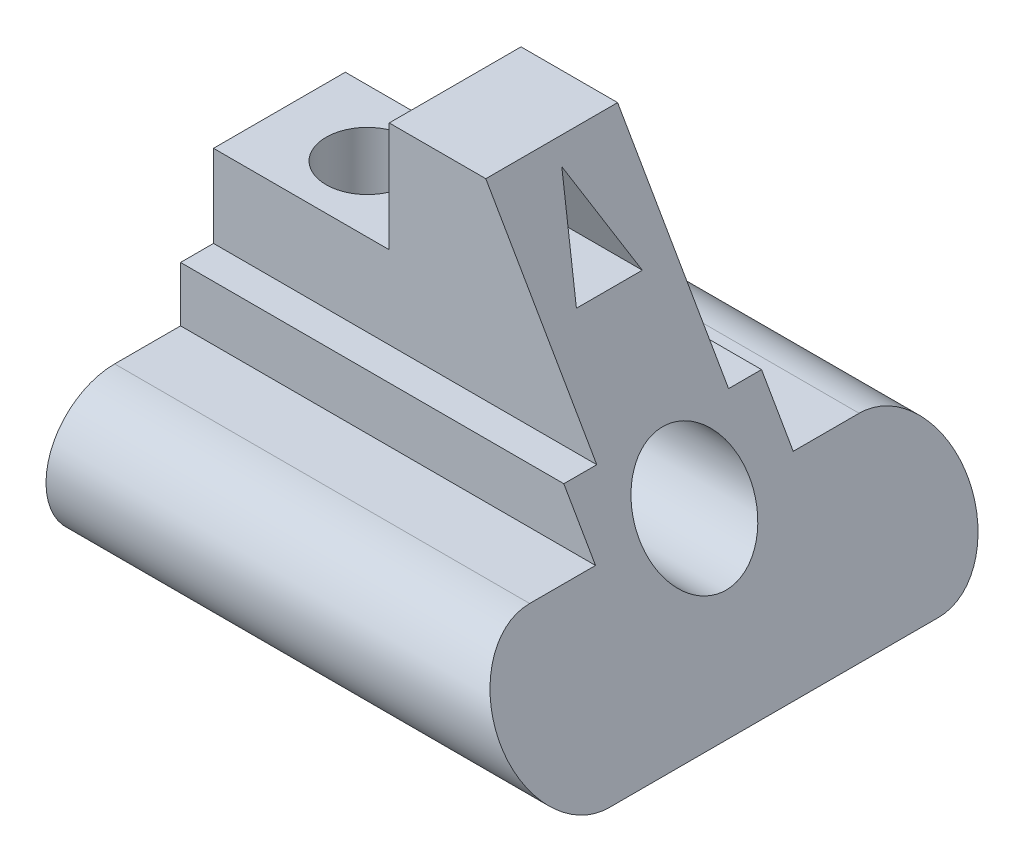
from build123d import *

# Parameters (mm, degrees)
SKETCH3_W               = 24
SKETCH3_H               = 35
BOSS_EXTRUDE1_DEPTH     = 90
SKETCH4_R               = 10
CUT_EXTRUDE1_DEPTH      = 91
SKETCH6_W               = 32
SKETCH6_H               = 24
CUT_EXTRUDE2_DEPTH      = 20
CUT_EXTRUDE4_REACH      = 52
SKETCH7_R               = 7.5
CUT_EXTRUDE5_DEPTH      = 31.5
CUT_EXTRUDE5_DEPTH_BACK = 55.5
CUT_EXTRUDE6_REACH      = 92


with BuildPart() as part:
    # Sketch3 → Boss-Extrude1 (new body)
    with BuildSketch(Plane(origin=(0, 0, 0), x_dir=(0, 0, -1), z_dir=(1, 0, 0))):
        with BuildLine():
            Line((-30, -12.5), (30, -12.5))
            ThreePointArc((30, -12.5), (42.5, 0), (30, 12.5))
            Line((30, 12.5), (-30, 12.5))
            ThreePointArc((-30, 12.5), (-42.5, 0), (-30, -12.5))
        make_face()
        Polygon((-18, 22.5), (-18, 12.5), (18, 12.5), (18, 22.5), (12, 22.5), (-12, 22.5), align=None)
        with Locations((0, 40)):
            Rectangle(SKETCH3_W, SKETCH3_H)
    extrude(amount=BOSS_EXTRUDE1_DEPTH)

    # Sketch4 → Cut-Extrude1 (cut, through all)
    with BuildSketch(Plane(origin=(90, 0, 0), x_dir=(0, 0, -1), z_dir=(1, 0, 0))):
        with Locations((0, 12.5)):
            Circle(SKETCH4_R)
    extrude(amount=-CUT_EXTRUDE1_DEPTH, mode=Mode.SUBTRACT)

    # Sketch6 → Cut-Extrude2 (cut)
    with BuildSketch(Plane(origin=(0, 57.5, 0), x_dir=(1, 0, 0), z_dir=(0, 1, 0))):
        with Locations((16, 0)):
            Rectangle(SKETCH6_W, SKETCH6_H)
    extrude(amount=-CUT_EXTRUDE2_DEPTH, mode=Mode.SUBTRACT)

    # Sketch7 → Cut-Extrude4 (cut, up to next)
    with BuildSketch(Plane(origin=(0, 37.5, 0), x_dir=(1, 0, 0), z_dir=(0, 1, 0)), mode=Mode.PRIVATE) as cut_extrude4_sk1:
        with Locations((16, 0)):
            Circle(SKETCH7_R)
    cut_extrude4_tool1 = extrude(cut_extrude4_sk1.sketch, amount=-CUT_EXTRUDE4_REACH, mode=Mode.PRIVATE) & part.part
    add(cut_extrude4_tool1.solids().sort_by_distance((16, 37.5, 0))[0], mode=Mode.SUBTRACT)

    # Sketch9 → Cut-Extrude5 (cut, two sides)
    with BuildSketch(Plane.XY.offset(12)) as cut_extrude5_sk:
        Polygon((90, 22.5), (90, 57.5), (49.585481157, 57.5), (90, -12.5), (90, 12.5), align=None)
    extrude(amount=CUT_EXTRUDE5_DEPTH, mode=Mode.SUBTRACT)
    extrude(cut_extrude5_sk.sketch, amount=-CUT_EXTRUDE5_DEPTH_BACK, mode=Mode.SUBTRACT)

    # Sketch15 → Cut-Extrude6 (cut, up to next)
    with BuildSketch(Plane(origin=(90, 0, 0), x_dir=(0, 0, -1), z_dir=(1, 0, 0)), mode=Mode.PRIVATE) as cut_extrude6_sk1:
        Polygon((0, 54.316366077), (-6, 39.316366077), (6, 39.316366077), align=None)
    cut_extrude6_tool1 = extrude(cut_extrude6_sk1.sketch, amount=-CUT_EXTRUDE6_REACH, mode=Mode.PRIVATE) & part.part
    add(cut_extrude6_tool1.solids().sort_by_distance((90, 44.316366, 0))[0], mode=Mode.SUBTRACT)


solid = part.part
